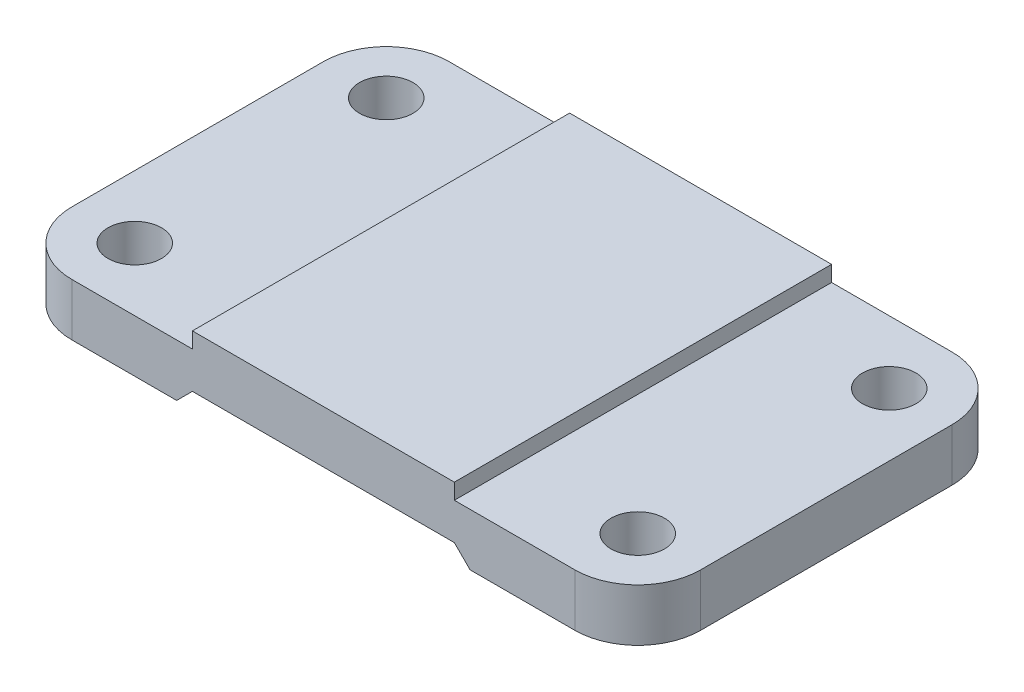
from build123d import *

# Parameters (mm, degrees)
SKETCH1_R           = 5.1
SKETCH1_W           = 50
SKETCH1_H           = 72
BOSS_EXTRUDE7_DEPTH = 10
CUT_EXTRUDE2_DEPTH  = 72
SKETCH7_W           = 50
SKETCH7_H           = 72
BOSS_EXTRUDE8_DEPTH = 3


with BuildPart() as part:
    # Sketch1 → Boss-Extrude7 (new body)
    with BuildSketch(Plane(origin=(0, 0, 0), x_dir=(1, 0, 0), z_dir=(0, 1, 0))):
        with BuildLine():
            ThreePointArc((0, 12), (3.514718626, 3.514718626), (12, 0))
            Line((12, 0), (35, 0))
            Line((35, 0), (35, 72))
            Line((35, 72), (12, 72))
            ThreePointArc((12, 72), (3.514718626, 68.485281374), (0, 60))
            Line((0, 60), (0, 12))
        make_face()
        with Locations((12, 12)):
            Circle(SKETCH1_R, mode=Mode.SUBTRACT)
        with Locations((12, 60)):
            Circle(SKETCH1_R, mode=Mode.SUBTRACT)
        with Locations((60, 36)):
            Rectangle(SKETCH1_W, SKETCH1_H)
        with BuildLine():
            Line((85, 72), (85, 0))
            Line((85, 0), (108, 0))
            ThreePointArc((108, 0), (116.485281374, 3.514718626), (120, 12))
            Line((120, 12), (120, 60))
            ThreePointArc((120, 60), (116.485281374, 68.485281374), (108, 72))
            Line((108, 72), (85, 72))
        make_face()
        with Locations((108, 12)):
            Circle(SKETCH1_R, mode=Mode.SUBTRACT)
        with Locations((108, 60)):
            Circle(SKETCH1_R, mode=Mode.SUBTRACT)
    extrude(amount=BOSS_EXTRUDE7_DEPTH)

    # Sketch5 → Cut-Extrude2 (cut)
    with BuildSketch(Plane.XY):
        Polygon((32, 0), (35, 3), (85, 3), (88, 0), align=None)
    extrude(amount=-CUT_EXTRUDE2_DEPTH, mode=Mode.SUBTRACT)

    # Sketch7 → Boss-Extrude8 (add)
    with BuildSketch(Plane(origin=(0, 10, 0), x_dir=(1, 0, 0), z_dir=(0, 1, 0))):
        with Locations((60, 36)):
            Rectangle(SKETCH7_W, SKETCH7_H)
    extrude(amount=BOSS_EXTRUDE8_DEPTH)


solid = part.part
